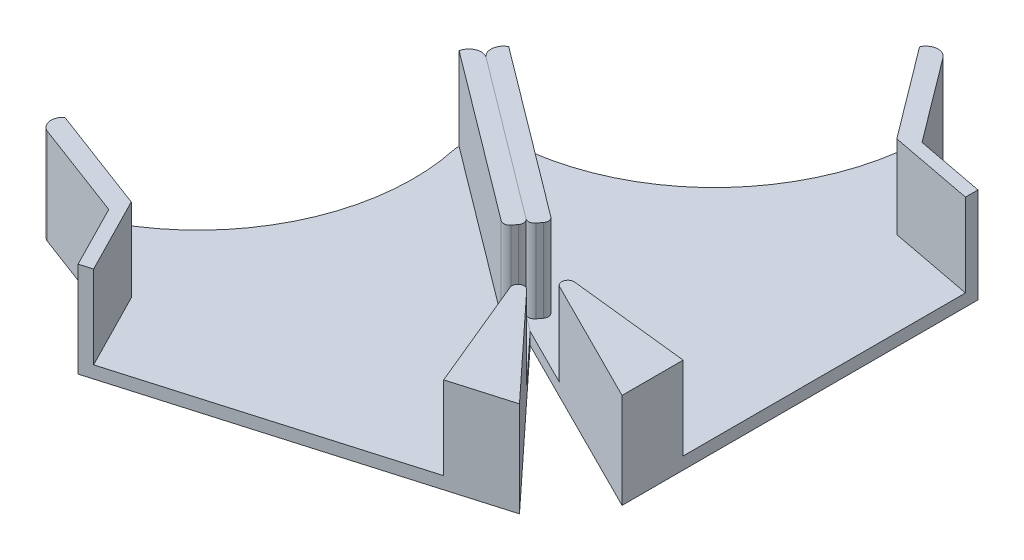
from build123d import *

# Parameters (mm, degrees)
EXTRUDE_1_DEPTH = 4
EXTRUDE_2_DEPTH = 27
FILLET_1_R      = 4
FILLET_2_R      = 2
FILLET_3_R      = 2


with BuildPart() as part:
    # Sketch 1 → Extrude 1 (new body)
    with BuildSketch(Plane(origin=(0, 0, 0), x_dir=(1, 0, 0), z_dir=(0, 1, 0))):
        with BuildLine():
            Line((-7.155589796286023, -69.6333076527855), (60, -120.00000000000001))
            Line((60, -120.00000000000001), (120.00000000000001, -150.10000000000002))
            Line((120.00000000000003, -150.10000000000002), (120, -34.29118010291478))
            Line((120, -34.29118010291478), (97.49999999999999, -30))
            Line((97.49999999999973, -30.000000000000192), (69.63330765278488, 7.1555897962855965))
            ThreePointArc((69.63330765278421, 7.155589796285523), (49.49747468305834, -49.497474683058314), (-7.155589796285488, -69.63330765278421))
        make_face()
    extrude(amount=EXTRUDE_1_DEPTH)

    # Sketch 3 → Extrude 2 (add)
    with BuildSketch(Plane(origin=(0, 4, 0), x_dir=(1, 0, 0), z_dir=(0, 1, 0))):
        with BuildLine():
            Line((120, -38.36327790348432), (120, -34.29118010291478))
            Line((120, -34.29118010291478), (97.5, -30))
            Line((97.49999999999973, -30.000000000000192), (69.63330765278488, 7.1555897962855965))
            ThreePointArc((69.63330765278421, 7.155589796285523), (69.97119240426343, 2.008042212092745), (69.92907057497307, -3.150410849466339))
            Line((69.92907057497204, -3.1504108494667022), (92.38930542603698, -33.097390650886666))
            Line((92.38930542603698, -33.097390650886666), (120, -38.36327790348432))
        make_face()
        Polygon((120.00000000000001, -150.10000000000002), (120.00000000000001, -130.2165964036135), (69.3067853264993, -124.66890397212713), align=None)
        with BuildLine():
            Line((59.67888894248035, -112.55416992559029), (2.8619555615955647, -69.94146988992675))
            ThreePointArc((2.861955561595763, -69.9414698899262), (-2.1523393613519746, -69.96690242731613), (-7.155589796285486, -69.63330765278421))
            Line((-7.155589796286165, -69.63330765278539), (56.220490487470755, -117.16536786560309))
            Line((56.220490487470755, -117.16536786560309), (59.67888894248035, -112.55416992559029))
        make_face()
    extrude(amount=EXTRUDE_2_DEPTH)

    # Fillet 1
    fillet_1_edges = [part.edges().sort_by_distance(p)[0] for p in [
        (-7.155589796285791, 15.5, 69.63330765278482),
        (69.63330765278454, 15.5, -7.155589796285559),
    ]]
    fillet(fillet_1_edges, radius=FILLET_1_R)

    # Fillet 2
    fillet_2_edges = [part.edges().sort_by_distance(p)[0] for p in [
        (69.3067853264993, 17.5, 124.66890397212714),
    ]]
    fillet(fillet_2_edges, radius=FILLET_2_R)

    # Fillet 3
    fillet_3_edges = [part.edges().sort_by_distance(p)[0] for p in [
        (56.220490487470755, 17.5, 117.16536786560309),
        (59.67888894248035, 17.5, 112.55416992559029),
    ]]
    fillet(fillet_3_edges, radius=FILLET_3_R)


with BuildPart() as body_2:
    # Mirror 3: mirrored copy
    add(part.part.mirror(Plane(origin=(-36.00000000000001, 4, 48.00000000000002), x_dir=(0.8, 0, 0.6), z_dir=(-0.5999999999999999, 0, 0.8))))


solid = Compound([part.part, body_2.part])
